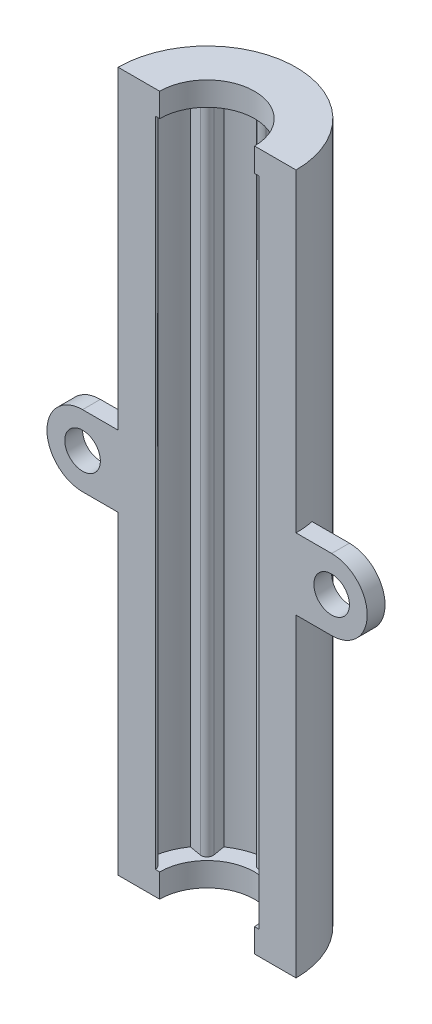
from build123d import *

# Parameters (mm, degrees)
SKETCH1_R               = 7.5
BOSS_EXTRUDE1_DEPTH     = 55
CUT_EXTRUDE2_DEPTH      = 57.013391256
SKETCH4_R               = 7.5
SKETCH4_R_2             = 4
BOSS_EXTRUDE2_DEPTH     = 2
LPATTERN1_COUNT         = 2
LPATTERN1_PITCH         = 57
SKETCH6_R               = 3
SKETCH6_R_2             = 1.5
BOSS_EXTRUDE3_DEPTH     = 1.5
SKETCH7_W               = 27
SKETCH7_H               = 7.5
CUT_EXTRUDE3_DEPTH      = 60.055059055
CUT_EXTRUDE3_DEPTH_BACK = 60.055059055


with BuildPart() as part:
    # Sketch1 → Boss-Extrude1 (new body)
    with BuildSketch(Plane(origin=(0, 0, 0), x_dir=(1, 0, 0), z_dir=(0, 1, 0))):
        with Locations(Location((0, 0, 0), (0, 0, 270))):
            Circle(SKETCH1_R)
    extrude(amount=BOSS_EXTRUDE1_DEPTH)

    # Sketch3 → Cut-Extrude2 (cut, through all)
    with BuildSketch(Plane(origin=(0, 55, 0), x_dir=(1, 0, 0), z_dir=(0, 1, 0))):
        with BuildLine():
            Line((-0.407679482, 4.574145986), (-1, 5.408326913))
            ThreePointArc((-1, 5.408326913), (-2.104758878, 5.081337429), (-3.117157854, 4.531371416))
            Line((-3.117157854, 4.531371416), (-2.946136719, 3.522682571))
            ThreePointArc((-2.946136719, 3.522682571), (-3.085548023, 3.085548023), (-3.522682571, 2.946136719))
            Line((-3.522682571, 2.946136719), (-4.531371416, 3.117157854))
            ThreePointArc((-4.531371416, 3.117157854), (-5.081337429, 2.104758878), (-5.408326913, 1))
            Line((-5.408326913, 1), (-4.574145986, 0.407679482))
            ThreePointArc((-4.574145986, 0.407679482), (-4.363623861, 0), (-4.574145986, -0.407679482))
            Line((-4.574145986, -0.407679482), (-5.408326913, -1))
            ThreePointArc((-5.408326913, -1), (-5.081337429, -2.104758878), (-4.531371416, -3.117157854))
            Line((-4.531371416, -3.117157854), (-3.522682571, -2.946136719))
            ThreePointArc((-3.522682571, -2.946136719), (-3.085548023, -3.085548023), (-2.946136719, -3.522682571))
            Line((-2.946136719, -3.522682571), (-3.117157854, -4.531371416))
            ThreePointArc((-3.117157854, -4.531371416), (-2.104758878, -5.081337429), (-1, -5.408326913))
            Line((-1, -5.408326913), (-0.407679482, -4.574145986))
            ThreePointArc((-0.407679482, -4.574145986), (0, -4.363623861), (0.407679482, -4.574145986))
            Line((0.407679482, -4.574145986), (1, -5.408326913))
            ThreePointArc((1, -5.408326913), (2.104758878, -5.081337429), (3.117157854, -4.531371416))
            Line((3.117157854, -4.531371416), (2.946136719, -3.522682571))
            ThreePointArc((2.946136719, -3.522682571), (3.085548023, -3.085548023), (3.522682571, -2.946136719))
            Line((3.522682571, -2.946136719), (4.531371416, -3.117157854))
            ThreePointArc((4.531371416, -3.117157854), (5.081337429, -2.104758878), (5.408326913, -1))
            Line((5.408326913, -1), (4.574145986, -0.407679482))
            ThreePointArc((4.574145986, -0.407679482), (4.363623861, 0), (4.574145986, 0.407679482))
            Line((4.574145986, 0.407679482), (5.408326913, 1))
            ThreePointArc((5.408326913, 1), (5.081337429, 2.104758878), (4.531371416, 3.117157854))
            Line((4.531371416, 3.117157854), (3.522682571, 2.946136719))
            ThreePointArc((3.522682571, 2.946136719), (3.085548023, 3.085548023), (2.946136719, 3.522682571))
            Line((2.946136719, 3.522682571), (3.117157854, 4.531371416))
            ThreePointArc((3.117157854, 4.531371416), (2.104758878, 5.081337429), (1, 5.408326913))
            Line((1, 5.408326913), (0.407679482, 4.574145986))
            ThreePointArc((0.407679482, 4.574145986), (0, 4.363623861), (-0.407679482, 4.574145986))
        make_face()
    extrude(amount=-CUT_EXTRUDE2_DEPTH, mode=Mode.SUBTRACT)

    # Sketch4 → Boss-Extrude2 (add)
    with BuildSketch(Plane(origin=(0, 0, 0), x_dir=(1, 0, 0), z_dir=(0, 1, 0))):
        with Locations(Location((0, 0, 0), (0, 0, 270))):
            Circle(SKETCH4_R)
        with Locations(Location((0, 0, 0), (0, 0, 270))):
            Circle(SKETCH4_R_2, mode=Mode.SUBTRACT)
    boss_extrude2 = extrude(amount=-BOSS_EXTRUDE2_DEPTH)

    # LPattern1: Boss-Extrude2 ×2
    with Locations(*[(0, i * LPATTERN1_PITCH, 0) for i in range(1, LPATTERN1_COUNT)]):
        add(boss_extrude2)

    # Sketch6 → Boss-Extrude3 (add, symmetric)
    with BuildSketch(Plane.XY):
        with BuildLine():
            Line((-6, 24.5), (-6, 30.5))
            Line((-6, 30.5), (-10.5, 30.5))
            ThreePointArc((-10.5, 30.5), (-8.378679656, 29.621320344), (-7.5, 27.5))
            ThreePointArc((-7.5, 27.5), (-8.378679656, 25.378679656), (-10.5, 24.5))
            Line((-10.5, 24.5), (-6, 24.5))
        make_face()
        with BuildLine():
            Line((10.5, 30.5), (6, 30.5))
            Line((6, 30.5), (6, 24.5))
            Line((6, 24.5), (10.499999991, 24.5))
            ThreePointArc((10.499999991, 24.5), (7.5, 27.500000005), (10.5, 30.5))
        make_face()
        with Locations((10.5, 27.5)):
            Circle(SKETCH6_R)
        with Locations((10.5, 27.5)):
            Circle(SKETCH6_R_2, mode=Mode.SUBTRACT)
        with Locations((-10.5, 27.5)):
            Circle(SKETCH6_R)
        with Locations((-10.5, 27.5)):
            Circle(SKETCH6_R_2, mode=Mode.SUBTRACT)
    extrude(amount=BOSS_EXTRUDE3_DEPTH, both=True)

    # Sketch7 → Cut-Extrude3 (cut, two sides)
    with BuildSketch(Plane(origin=(0, 0, 0), x_dir=(1, 0, 0), z_dir=(0, 1, 0))) as cut_extrude3_sk:
        with Locations((0, -3.75)):
            Rectangle(SKETCH7_W, SKETCH7_H)
    extrude(amount=CUT_EXTRUDE3_DEPTH, mode=Mode.SUBTRACT)
    extrude(cut_extrude3_sk.sketch, amount=-CUT_EXTRUDE3_DEPTH_BACK, mode=Mode.SUBTRACT)


solid = part.part
